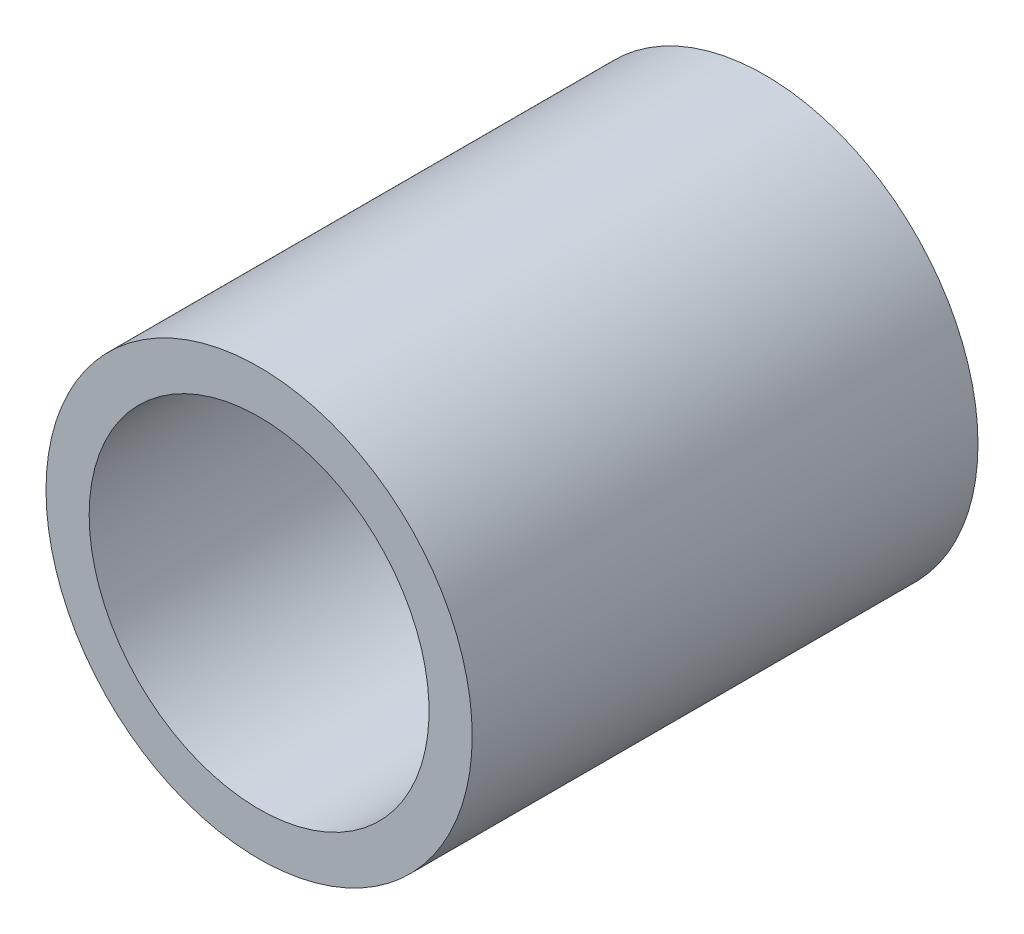
from build123d import *

# Parameters (mm, degrees)
SKETCH5_R           = 4.0132
SKETCH5_R_2         = 3.2004
BOSS_EXTRUDE1_DEPTH = 4.7625


with BuildPart() as part:
    # Sketch5 → Boss-Extrude1 (new, symmetric)
    with BuildSketch(Plane.XY):
        with Locations(Location((0, 0, 0), (0, 0, 180))):
            Circle(SKETCH5_R)
        with Locations(Location((0, 0, 0), (0, 0, 180))):
            Circle(SKETCH5_R_2, mode=Mode.SUBTRACT)
    extrude(amount=BOSS_EXTRUDE1_DEPTH, both=True)


solid = part.part
